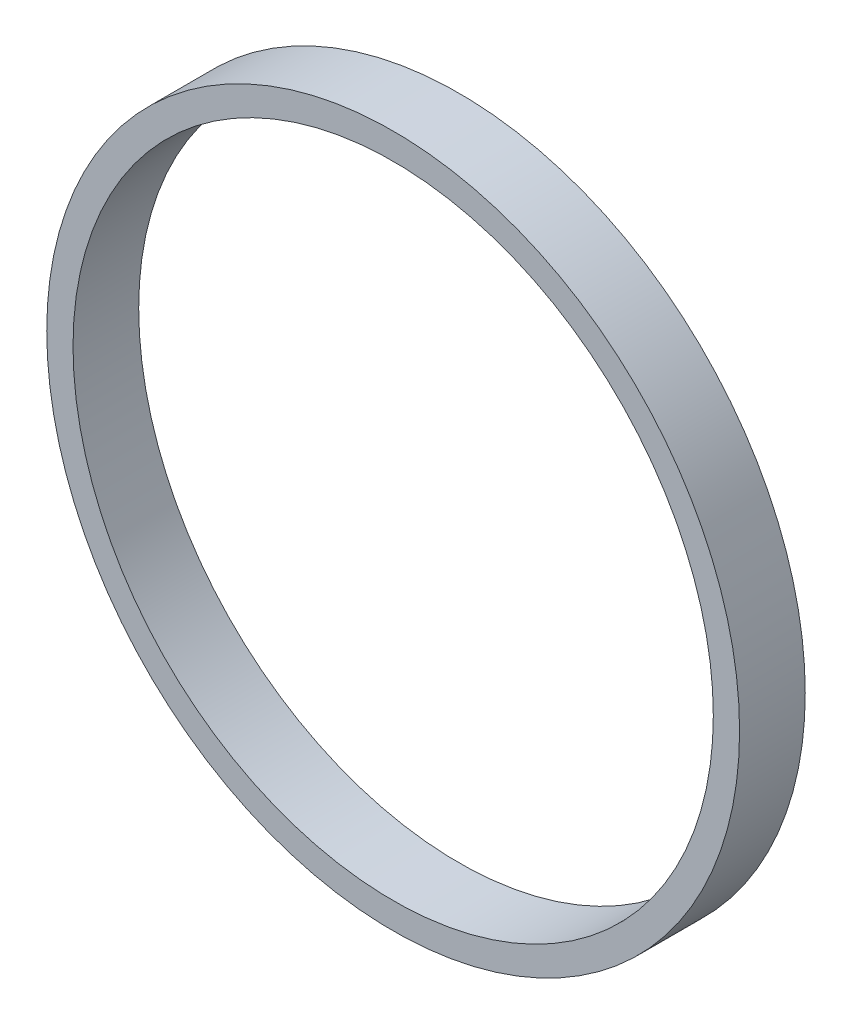
from build123d import *

# Parameters (mm, degrees)
SKETCH1_R           = 52.75
SKETCH1_R_2         = 48.75
EXTRUDE_THIN1_DEPTH = 10


with BuildPart() as part:
    # Sketch1 → Extrude-Thin1 (new body)
    with BuildSketch(Plane.XY):
        Circle(SKETCH1_R)
        Circle(SKETCH1_R_2, mode=Mode.SUBTRACT)
    extrude(amount=EXTRUDE_THIN1_DEPTH)


solid = part.part
